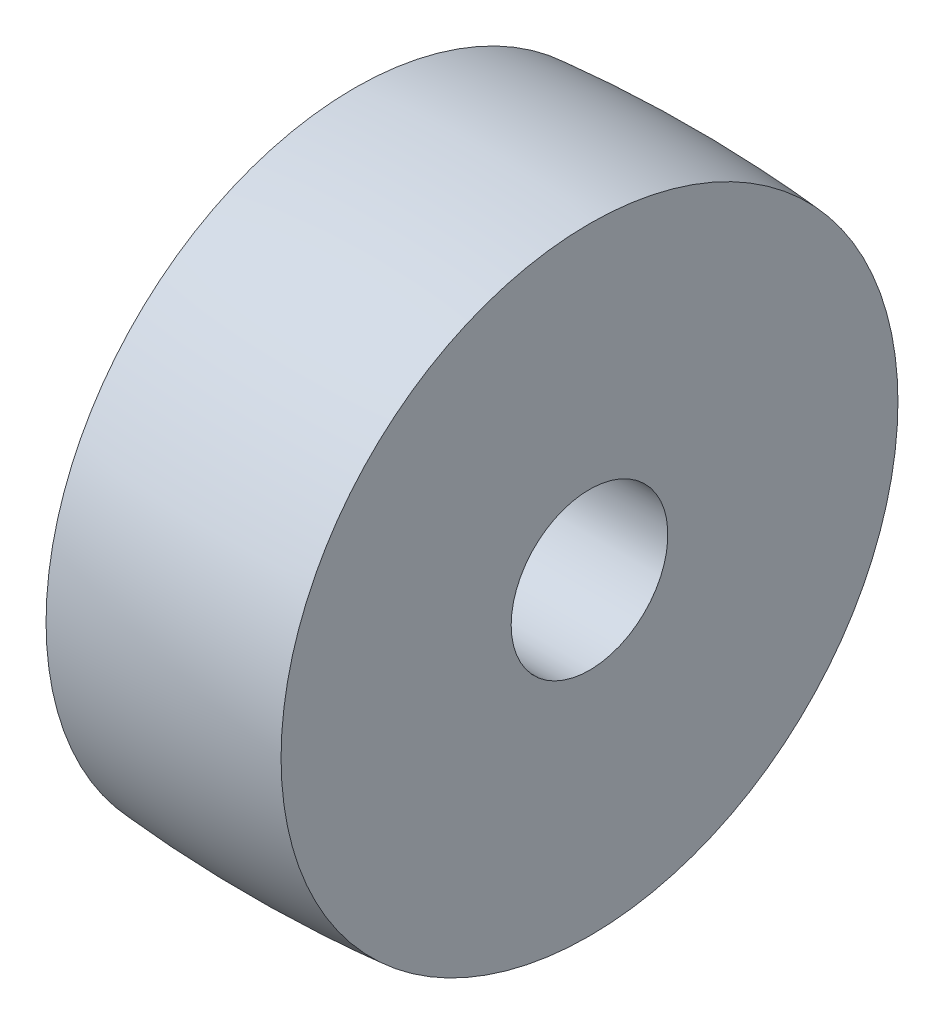
from build123d import *


with BuildPart() as part:
    # Sketch1 → Revolve1 (revolve)
    with BuildSketch(Plane.XY):
        with BuildLine():
            Line((-38.1, 25.4), (38.1, 25.4))
            Line((38.1, 25.4), (38.1, 100.0125))
            ThreePointArc((38.1, 100.0125), (0, 101.6), (-38.1, 100.0125))
            Line((-38.1, 100.0125), (-38.1, 25.4))
        make_face()
    revolve(axis=Axis((-41.91, 0, 0), (1, 0, 0)))


solid = part.part
